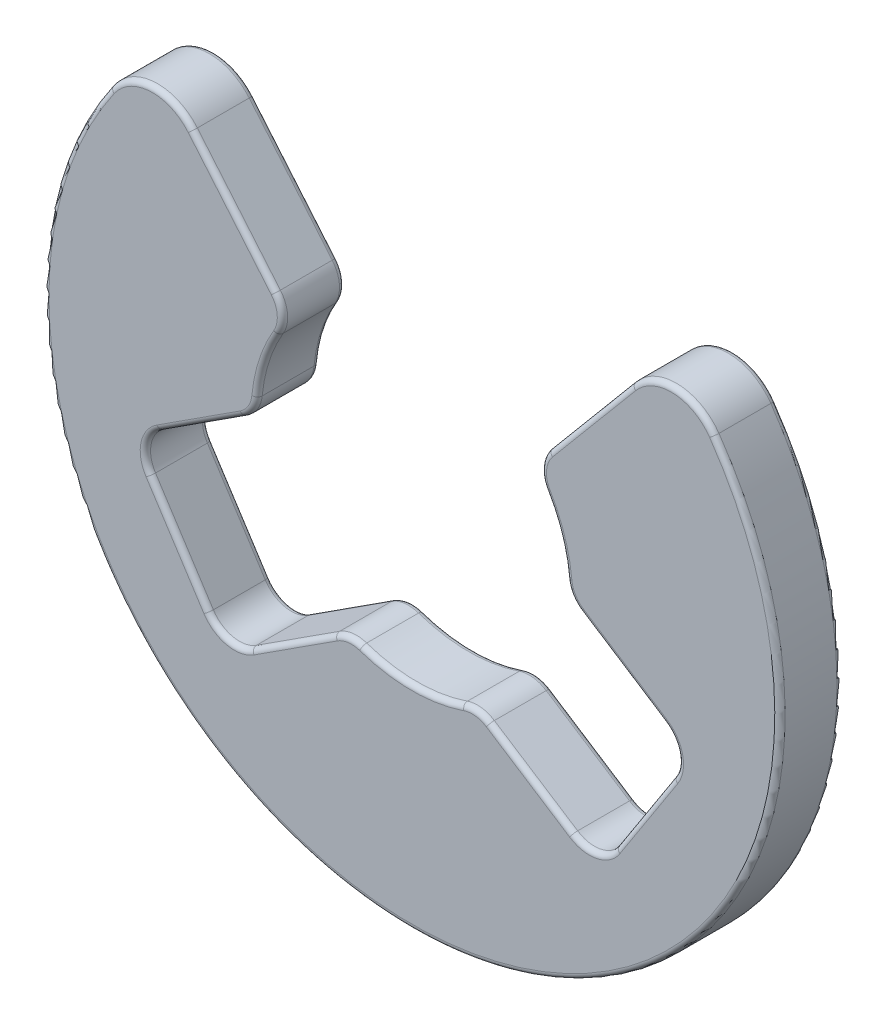
from build123d import *

# Parameters (mm, degrees)
BOSS_EXTRUDE1_DEPTH = 0.6
FILLET1_R           = 0.5
FILLET2_R           = 0.3
FILLET3_R           = 0.3
FILLET4_R           = 0.05


with BuildPart() as part:
    # Sketch1 → Boss-Extrude1 (new body)
    with BuildSketch(Plane.XY):
        with BuildLine():
            Line((1.171346259, 0.936988763), (2.5, 2.520416632))
            ThreePointArc((2.5, 2.520416632), (0, -3.55), (-2.5, 2.520416632))
            Line((-2.5, 2.520416632), (-1.171346259, 0.936988763))
            ThreePointArc((-1.171346259, 0.936988763), (-1.415453883, 0.496477901), (-1.5, 0))
            Line((-1.5, 0), (-2.684811412, -0.765561301))
            Line((-2.684811412, -0.765561301), (-1.801206343, -2.13306168))
            Line((-1.801206343, -2.13306168), (-0.616394931, -1.36750038))
            ThreePointArc((-0.616394931, -1.36750038), (0, -1.5), (0.616394931, -1.36750038))
            Line((0.616394931, -1.36750038), (1.801206343, -2.13306168))
            Line((1.801206343, -2.13306168), (2.684811412, -0.765561301))
            Line((2.684811412, -0.765561301), (1.5, 0))
            ThreePointArc((1.5, 0), (1.415453883, 0.496477901), (1.171346259, 0.936988763))
        make_face()
    extrude(amount=BOSS_EXTRUDE1_DEPTH)

    # Fillet1
    fillet1_edges = [part.edges().sort_by_distance(p)[0] for p in [
        (2.5, 2.520416632, 0.3),
        (-2.5, 2.520416632, 0.3),
    ]]
    fillet(fillet1_edges, radius=FILLET1_R)

    # Fillet2
    fillet2_edges = [part.edges().sort_by_distance(p)[0] for p in [
        (1.171346259, 0.936988763, 0.3),
        (-1.171346259, 0.936988763, 0.3),
        (-1.5, 0, 0.3),
        (-0.616394931, -1.36750038, 0.3),
        (0.616394931, -1.36750038, 0.3),
        (1.5, 0, 0.3),
    ]]
    fillet(fillet2_edges, radius=FILLET2_R)

    # Fillet3
    fillet3_edges = [part.edges().sort_by_distance(p)[0] for p in [
        (-2.684811412, -0.765561301, 0.3),
        (-1.801206343, -2.13306168, 0.3),
        (1.801206343, -2.13306168, 0.3),
        (2.684811412, -0.765561301, 0.3),
    ]]
    fillet(fillet3_edges, radius=FILLET3_R)

    # Fillet4
    fillet4_edges = [part.edges().sort_by_distance(p)[0] for p in [
        (1.718348073, 1.58888014, 0),
        (1.718348073, 1.58888014, 0.6),
        (0, -3.55, 0),
        (-2.524033807, 2.244140397, 0),
        (2.524033807, 2.244140397, 0),
        (0, -3.55, 0.6),
        (-2.524033807, 2.244140397, 0.6),
        (2.524033807, 2.244140397, 0.6),
        (0, -1.5, 0),
        (0, -1.5, 0.6),
        (-1.718348073, 1.58888014, 0),
        (-1.42631662, 0.464349974, 0),
        (-1.14745701, -1.710644083, 0),
        (2.031062079, -0.343143703, 0),
        (1.42631662, 0.464349974, 0),
        (-1.248772298, 0.943221645, 0),
        (-1.535629659, 0.012802345, 0),
        (1.248772298, 0.943221645, 0),
        (1.535629659, 0.012802345, 0),
        (-0.619364751, -1.405243629, 0),
        (0.619364751, -1.405243629, 0),
        (1.42631662, 0.464349974, 0.6),
        (2.031062079, -0.343143703, 0.6),
        (-1.14745701, -1.710644083, 0.6),
        (-1.42631662, 0.464349974, 0.6),
        (-1.718348073, 1.58888014, 0.6),
        (-1.248772298, 0.943221645, 0.6),
        (-1.535629659, 0.012802345, 0.6),
        (1.248772298, 0.943221645, 0.6),
        (1.535629659, 0.012802345, 0.6),
        (-0.619364751, -1.405243629, 0.6),
        (0.619364751, -1.405243629, 0.6),
        (-2.243008878, -1.44931149, 0),
        (-2.243008878, -1.44931149, 0.6),
        (-2.031062079, -0.343143703, 0),
        (-2.031062079, -0.343143703, 0.6),
        (1.14745701, -1.710644083, 0),
        (1.14745701, -1.710644083, 0.6),
        (2.243008878, -1.44931149, 0),
        (2.243008878, -1.44931149, 0.6),
        (-1.775091209, -2.011572757, 0),
        (-1.775091209, -2.011572757, 0.6),
        (-2.563322488, -0.791676435, 0),
        (-2.563322488, -0.791676435, 0.6),
        (1.775091209, -2.011572757, 0),
        (1.775091209, -2.011572757, 0.6),
        (2.563322488, -0.791676435, 0),
        (2.563322488, -0.791676435, 0.6),
    ]]
    fillet(fillet4_edges, radius=FILLET4_R)


solid = part.part
